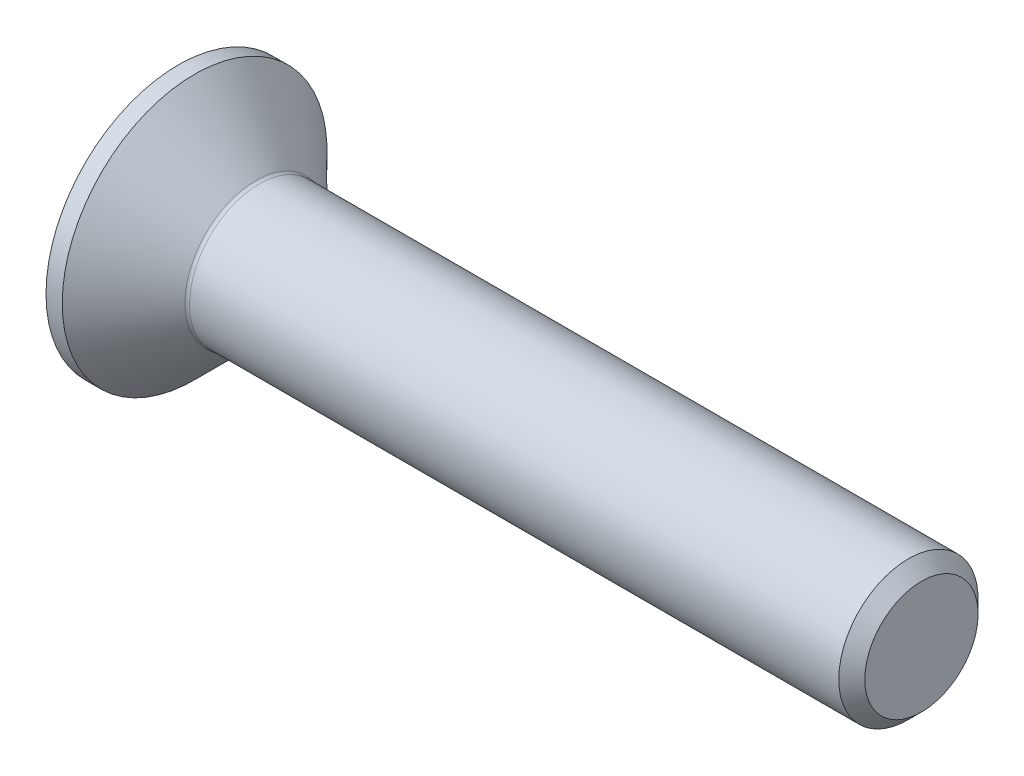
from build123d import *

# Parameters (mm, degrees)
FILLET1_R   = 0.1
HEX_2_DEPTH = 1.2


with BuildPart() as part:
    # BodySke → BaseBody (revolve)
    with BuildSketch(Plane.XY):
        Polygon((0, 0), (0, 2.85), (0.35, 2.85), (1.7, 1.5), (15.7195, 1.5), (16, 1.2195), (16, 0), align=None)
    revolve(axis=Axis((0, 0, 0), (1, 0, 0)))

    # Fillet1
    fillet1_edges = [part.edges().sort_by_distance(p)[0] for p in [
        (1.7, -1.5, 0),
    ]]
    fillet(fillet1_edges, radius=FILLET1_R)

    # Sketch2 → PreBroach (revolve, cut)
    with BuildSketch(Plane.XY):
        Polygon((0, 1.01), (1.2, 1.01), (1.783123772, 0), (0, 0), align=None)
    revolve(axis=Axis((0, 0, 0), (1, 0, 0)), mode=Mode.SUBTRACT)

    # Sketch3 → Hex 2 (cut)
    with BuildSketch(Plane.ZY):
        Polygon((-1.01, -0.583123772), (-1.01, 0.583123772), (0, 1.166247544), (1.01, 0.583123772), (1.01, -0.583123772), (0, -1.166247544), align=None)
    extrude(amount=-HEX_2_DEPTH, mode=Mode.SUBTRACT)


solid = part.part
